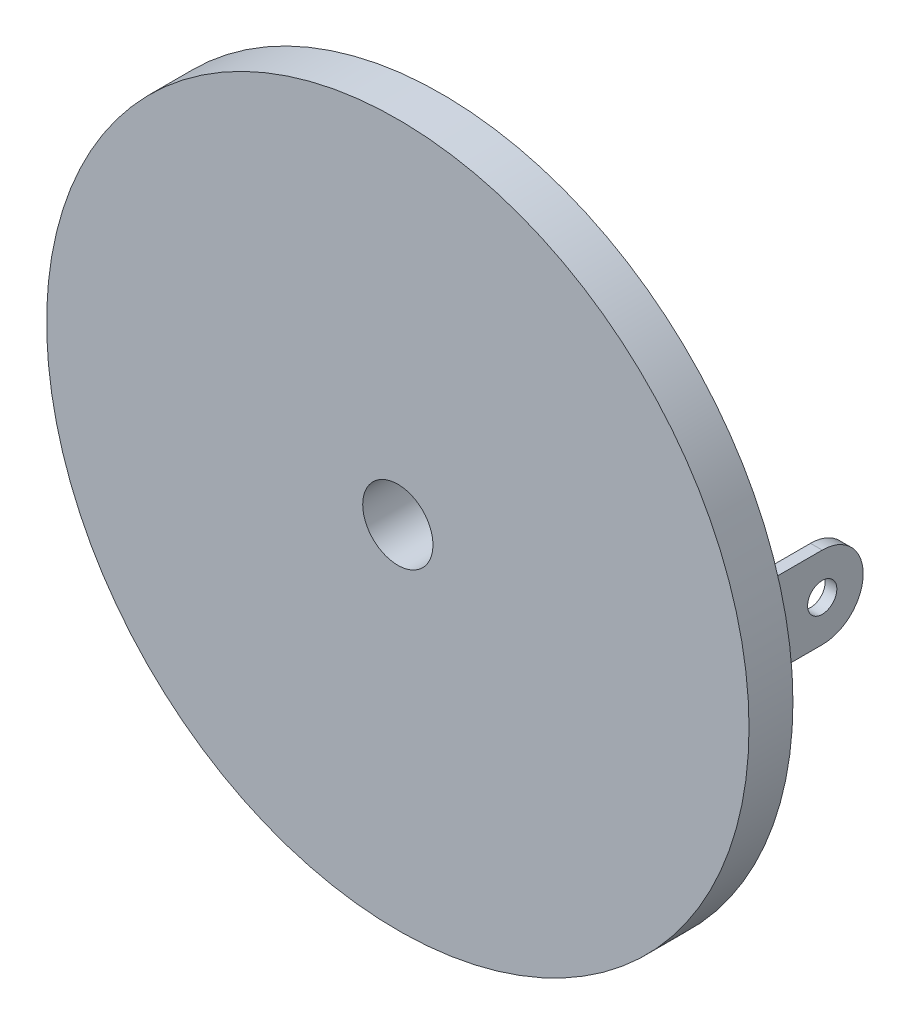
from build123d import *

# Parameters (mm, degrees)
ESQUISSE1_R             = 12
EXTRUSION1_DEPTH        = 1.5
ESQUISSE2_W             = 0.4
ESQUISSE2_H             = 2.8
EXTRUSION2_DEPTH        = 5
ESQUISSE3_R             = 4.2
EXTRUSION3_DEPTH        = 2
ESQUISSE4_R             = 0.5
ENL_V_MAT_EXTRU_1_DEPTH = 22.4
ESQUISSE5_R             = 1.2
ENL_V_MAT_EXTRU_2_DEPTH = 4.5


with BuildPart() as part:
    # Esquisse1 → Extrusion1 (new body)
    with BuildSketch(Plane.XY):
        Circle(ESQUISSE1_R)
    extrude(amount=EXTRUSION1_DEPTH)

    # Esquisse2 → Extrusion2 (add)
    with BuildSketch(Plane(origin=(0, 0, 0), x_dir=(-1, 0, 0), z_dir=(0, 0, -1))):
        with Locations((9.2, 0)):
            Rectangle(ESQUISSE2_W, ESQUISSE2_H)
        with Locations((-9.2, 0)):
            Rectangle(ESQUISSE2_W, ESQUISSE2_H)
    extrude(amount=EXTRUSION2_DEPTH)

    # Esquisse3 → Extrusion3 (add)
    with BuildSketch(Plane(origin=(0, 0, 0), x_dir=(-1, 0, 0), z_dir=(0, 0, -1))):
        with Locations(Location((0, 0, 0), (0, 0, 180))):  # turned: the seam where the file's is
            Circle(ESQUISSE3_R)
    extrude(amount=EXTRUSION3_DEPTH)

    # Esquisse4 → Enlèv. mat.-Extru.1 (cut, through all)
    with BuildSketch(Plane(origin=(9.4, 0, 0), x_dir=(0, 0, -1), z_dir=(1, 0, 0))):
        with Locations((3.6, 0)):
            Circle(ESQUISSE4_R)
        with BuildLine():
            Line((3.6, 1.4), (3.6, 1.511382549))
            Line((3.6, 1.511382549), (5.122212009, 1.511382549))
            Line((5.122212009, 1.511382549), (5.122212009, -1.492036709))
            Line((5.122212009, -1.492036709), (3.6, -1.492036709))
            Line((3.6, -1.492036709), (3.6, -1.4))
            ThreePointArc((3.6, -1.4), (5, 0), (3.6, 1.4))
        make_face()
    extrude(amount=-ENL_V_MAT_EXTRU_1_DEPTH, mode=Mode.SUBTRACT)

    # Esquisse5 → Enlèv. mat.-Extru.2 (cut, through all)
    with BuildSketch(Plane(origin=(0, 0, -2), x_dir=(-1, 0, 0), z_dir=(0, 0, -1))):
        Circle(ESQUISSE5_R)
    extrude(amount=-ENL_V_MAT_EXTRU_2_DEPTH, mode=Mode.SUBTRACT)


solid = part.part
